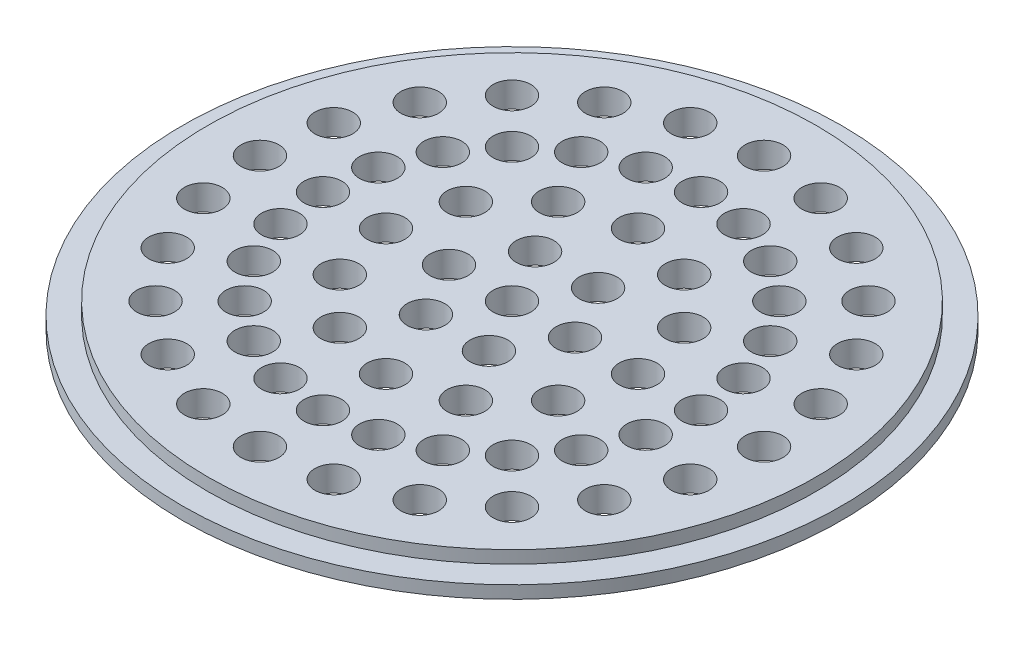
from build123d import *

# Parameters (mm, degrees)
SKETCH_1_R          = 26.15
EXTRUDE_1_DEPTH     = 1
SKETCH_2_R          = 24.15
EXTRUDE_2_DEPTH     = 1
SKETCH_3_R          = 1.5
CUT_EXTRUDE_1_DEPTH = 3


with BuildPart() as part:
    # Эскиз1 → Бобышка-Вытянуть1 (new body)
    with BuildSketch(Plane(origin=(0, 0, 0), x_dir=(1, 0, 0), z_dir=(0, 1, 0))):
        Circle(SKETCH_1_R)
    extrude(amount=EXTRUDE_1_DEPTH)

    # Эскиз2 → Бобышка-Вытянуть2 (add)
    with BuildSketch(Plane(origin=(0, 1, 0), x_dir=(1, 0, 0), z_dir=(0, 1, 0))):
        Circle(SKETCH_2_R)
    extrude(amount=EXTRUDE_2_DEPTH)

    # Эскиз3 → Вырез-Вытянуть1 (cut, through all)
    with BuildSketch(Plane(origin=(0, 2, 0), x_dir=(1, 0, 0), z_dir=(0, 1, 0))):
        Circle(SKETCH_3_R)
        with Locations((5, 0)):
            Circle(SKETCH_3_R)
        with Locations((10, 0)):
            Circle(SKETCH_3_R)
        with Locations((15, 0)):
            Circle(SKETCH_3_R)
        with Locations((20, 0)):
            Circle(SKETCH_3_R)
        with Locations((2.5, -4.330127019)):
            Circle(SKETCH_3_R)
        with Locations((5, -8.660254038)):
            Circle(SKETCH_3_R)
        with Locations((7.5, -12.990381057)):
            Circle(SKETCH_3_R)
        with Locations((10, -17.320508076)):
            Circle(SKETCH_3_R)
        with Locations((-2.5, -4.330127019)):
            Circle(SKETCH_3_R)
        with Locations((-5, -8.660254038)):
            Circle(SKETCH_3_R)
        with Locations((-7.5, -12.990381057)):
            Circle(SKETCH_3_R)
        with Locations((-10, -17.320508076)):
            Circle(SKETCH_3_R)
        with Locations((-5, 0)):
            Circle(SKETCH_3_R)
        with Locations((-10, 0)):
            Circle(SKETCH_3_R)
        with Locations((-15, 0)):
            Circle(SKETCH_3_R)
        with Locations((-20, 0)):
            Circle(SKETCH_3_R)
        with Locations((-2.5, 4.330127019)):
            Circle(SKETCH_3_R)
        with Locations((-5, 8.660254038)):
            Circle(SKETCH_3_R)
        with Locations((-7.5, 12.990381057)):
            Circle(SKETCH_3_R)
        with Locations((-10, 17.320508076)):
            Circle(SKETCH_3_R)
        with Locations((2.5, 4.330127019)):
            Circle(SKETCH_3_R)
        with Locations((5, 8.660254038)):
            Circle(SKETCH_3_R)
        with Locations((7.5, 12.990381057)):
            Circle(SKETCH_3_R)
        with Locations((10, 17.320508076)):
            Circle(SKETCH_3_R)
        with Locations((8.660254038, -5)):
            Circle(SKETCH_3_R)
        with Locations((12.990381057, -7.5)):
            Circle(SKETCH_3_R)
        with Locations((17.320508076, -10)):
            Circle(SKETCH_3_R)
        with Locations((0, -10)):
            Circle(SKETCH_3_R)
        with Locations((0, -15)):
            Circle(SKETCH_3_R)
        with Locations((0, -20)):
            Circle(SKETCH_3_R)
        with Locations((-8.660254038, -5)):
            Circle(SKETCH_3_R)
        with Locations((-12.990381057, -7.5)):
            Circle(SKETCH_3_R)
        with Locations((-17.320508076, -10)):
            Circle(SKETCH_3_R)
        with Locations((-8.660254038, 5)):
            Circle(SKETCH_3_R)
        with Locations((-12.990381057, 7.5)):
            Circle(SKETCH_3_R)
        with Locations((-17.320508076, 10)):
            Circle(SKETCH_3_R)
        with Locations((0, 10)):
            Circle(SKETCH_3_R)
        with Locations((0, 15)):
            Circle(SKETCH_3_R)
        with Locations((0, 20)):
            Circle(SKETCH_3_R)
        with Locations((8.660254038, 5)):
            Circle(SKETCH_3_R)
        with Locations((12.990381057, 7.5)):
            Circle(SKETCH_3_R)
        with Locations((17.320508076, 10)):
            Circle(SKETCH_3_R)
        with Locations((14.488887394, -3.882285677)):
            Circle(SKETCH_3_R)
        with Locations((19.318516526, -5.176380902)):
            Circle(SKETCH_3_R)
        with Locations((10.606601718, -10.606601718)):
            Circle(SKETCH_3_R)
        with Locations((14.142135624, -14.142135624)):
            Circle(SKETCH_3_R)
        with Locations((3.882285677, -14.488887394)):
            Circle(SKETCH_3_R)
        with Locations((5.176380902, -19.318516526)):
            Circle(SKETCH_3_R)
        with Locations((-3.882285677, -14.488887394)):
            Circle(SKETCH_3_R)
        with Locations((-5.176380902, -19.318516526)):
            Circle(SKETCH_3_R)
        with Locations((-10.606601718, -10.606601718)):
            Circle(SKETCH_3_R)
        with Locations((-14.142135624, -14.142135624)):
            Circle(SKETCH_3_R)
        with Locations((-14.488887394, -3.882285677)):
            Circle(SKETCH_3_R)
        with Locations((-19.318516526, -5.176380902)):
            Circle(SKETCH_3_R)
        with Locations((-14.488887394, 3.882285677)):
            Circle(SKETCH_3_R)
        with Locations((-19.318516526, 5.176380902)):
            Circle(SKETCH_3_R)
        with Locations((-10.606601718, 10.606601718)):
            Circle(SKETCH_3_R)
        with Locations((-14.142135624, 14.142135624)):
            Circle(SKETCH_3_R)
        with Locations((-3.882285677, 14.488887394)):
            Circle(SKETCH_3_R)
        with Locations((-5.176380902, 19.318516526)):
            Circle(SKETCH_3_R)
        with Locations((3.882285677, 14.488887394)):
            Circle(SKETCH_3_R)
        with Locations((5.176380902, 19.318516526)):
            Circle(SKETCH_3_R)
        with Locations((10.606601718, 10.606601718)):
            Circle(SKETCH_3_R)
        with Locations((14.142135624, 14.142135624)):
            Circle(SKETCH_3_R)
        with Locations((14.488887394, 3.882285677)):
            Circle(SKETCH_3_R)
        with Locations((19.318516526, 5.176380902)):
            Circle(SKETCH_3_R)
    extrude(amount=-CUT_EXTRUDE_1_DEPTH, mode=Mode.SUBTRACT)


solid = part.part
